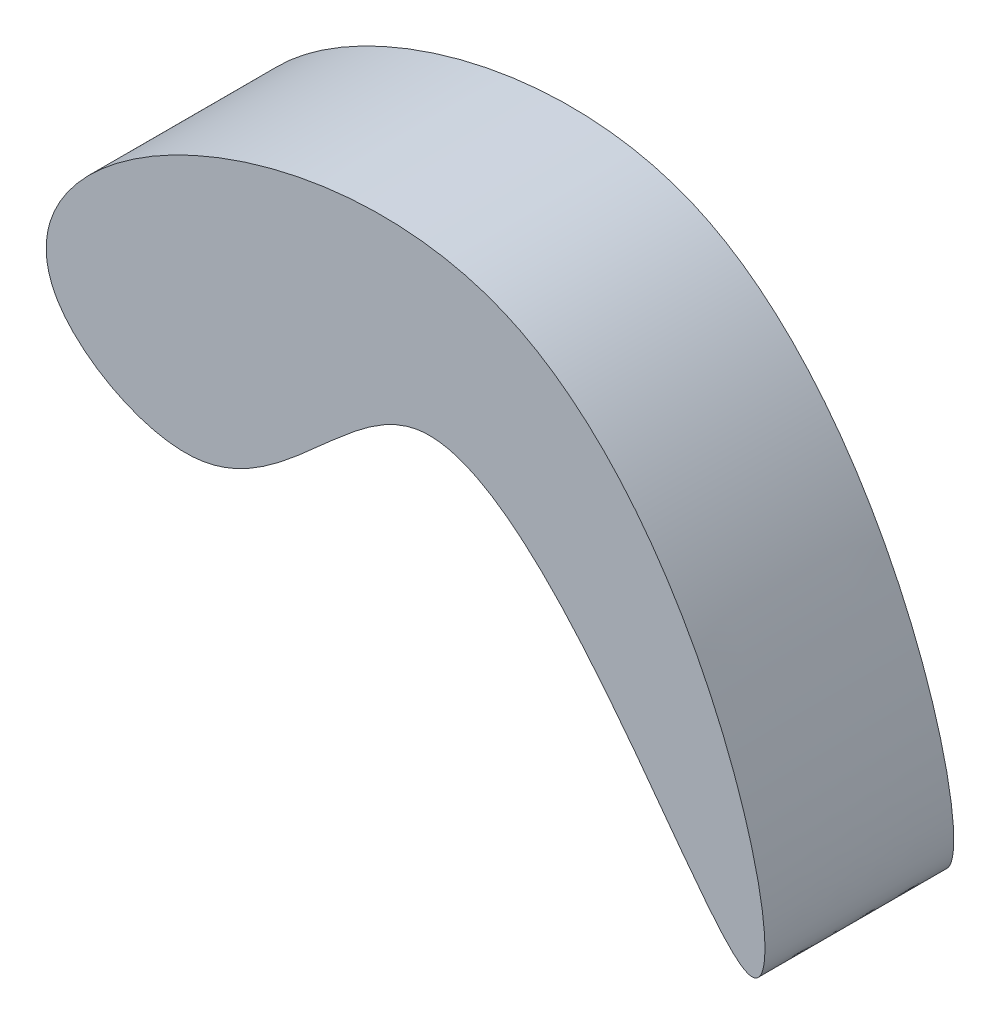
from build123d import *

# Parameters (mm, degrees)
BOSS_EXTRUDE1_DEPTH      = 7
BOSS_EXTRUDE1_DEPTH_BACK = 10


with BuildPart() as part:
    # Sketch1 → Boss-Extrude1 (new body, two sides)
    with BuildSketch(Plane.XY) as boss_extrude1_sk:
        with BuildLine():
            add(Edge.make_bspline(
                [(3.566645753, 23.219455359), (-3.342210286, 34.40736237), (55.287083173, 66.680411296), (77.598281444, -28.879547073), (39.24526533, 47.104295428), (20.756872815, 11.580896394), (5.695153837, 19.772640086), (3.566645753, 23.219455359)],
                knots=[0, 0, 0, 0, 0.264443018, 0.537803526, 0.777723672, 0.918529334, 1, 1, 1, 1], degree=3))
        make_face()
    extrude(amount=BOSS_EXTRUDE1_DEPTH)
    extrude(boss_extrude1_sk.sketch, amount=-BOSS_EXTRUDE1_DEPTH_BACK)


solid = part.part
